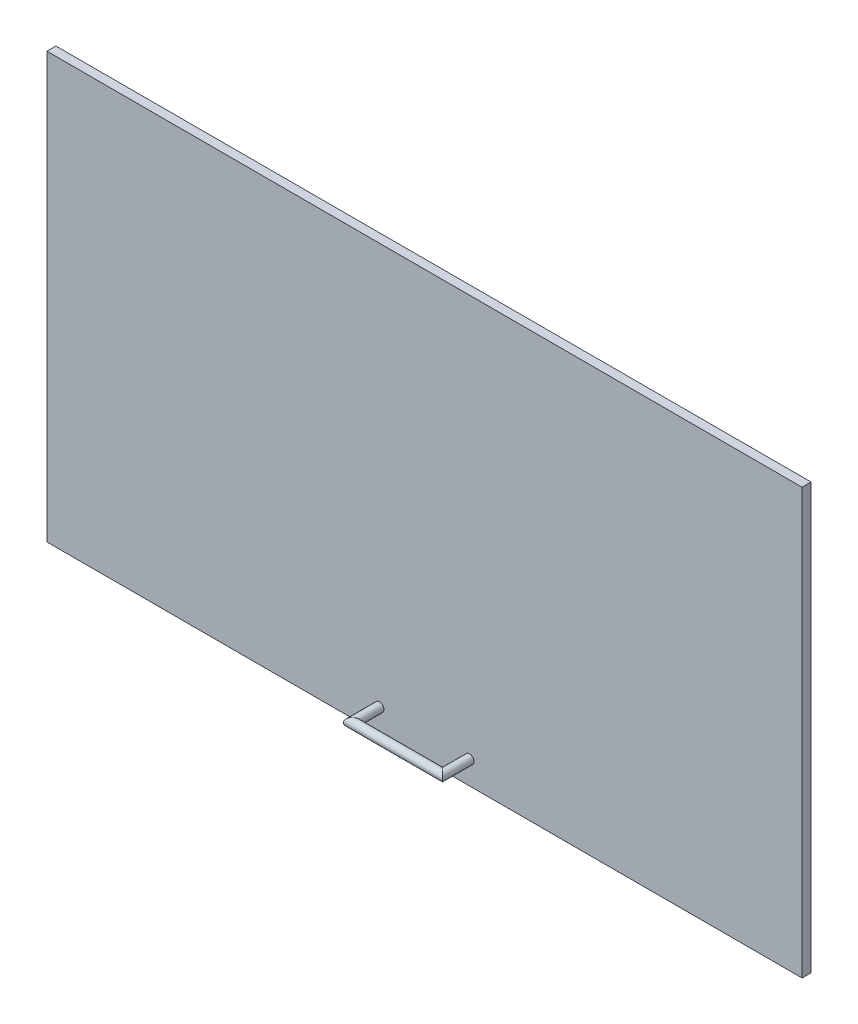
from build123d import *

# Parameters (mm, degrees)
SKETCH1_W           = 838.48
SKETCH1_H           = 471.91
BOSS_EXTRUDE1_DEPTH = 10
SKETCH2_R           = 5


with BuildPart() as part:
    # Sketch1 → Boss-Extrude1 (new body)
    with BuildSketch(Plane.XY):
        Rectangle(SKETCH1_W, SKETCH1_H)
    extrude(amount=BOSS_EXTRUDE1_DEPTH)

    # Sweep3: sweep along a curve in space
    with BuildLine() as sweep3_path:
        Line((-50, -210, 10), (-50, -210, 40))
        Line((50, -210, 40), (-50, -210, 40))
        Line((50, -210, 10), (50, -210, 40))
    # Sketch2 → Sweep3 (sweep)
    with BuildSketch(Plane.XY.offset(10)):
        with Locations((50, -210)):
            Circle(SKETCH2_R)
    sweep(path=sweep3_path.line, transition=Transition.RIGHT)


solid = part.part
